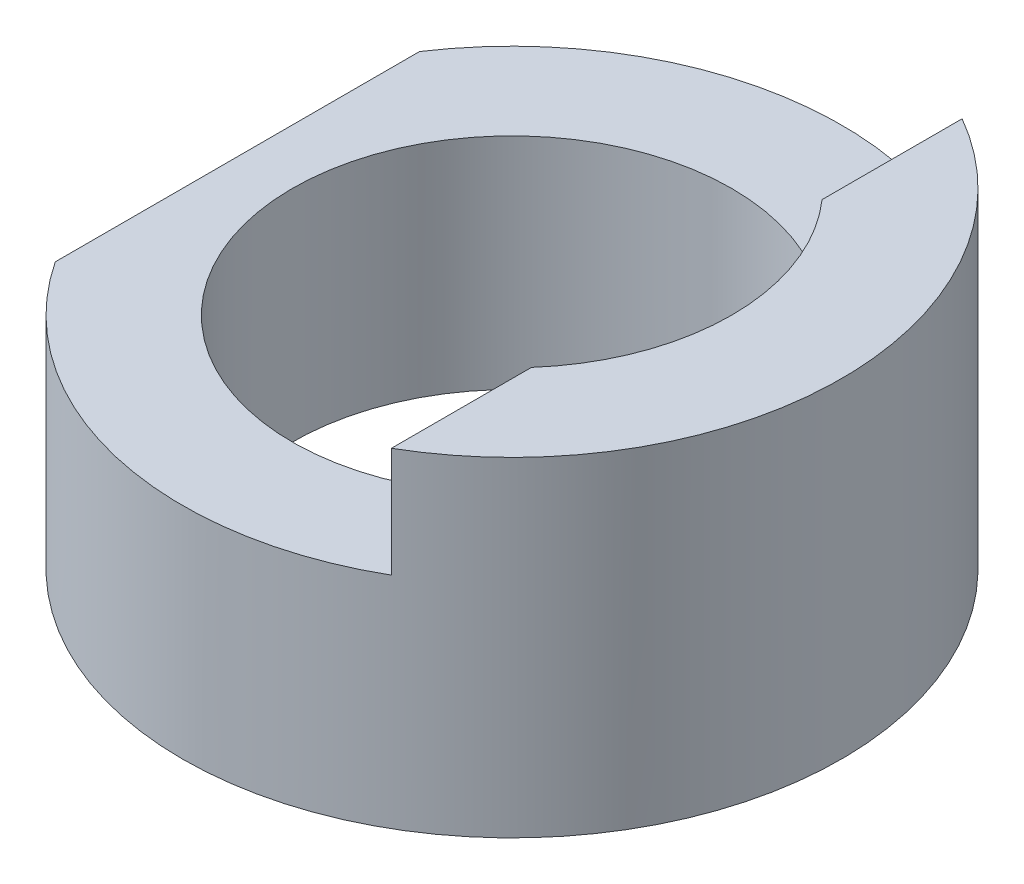
from build123d import *

# Parameters (mm, degrees)
SKETCH1_W           = 120
SKETCH1_H           = 60
BOSS_EXTRUDE1_DEPTH = 120
CUT_EXTRUDE1_DEPTH  = 120
CUT_EXTRUDE2_DEPTH  = 120
SKETCH5_R           = 40
CUT_EXTRUDE3_DEPTH  = 120


with BuildPart() as part:
    # Sketch1 → Boss-Extrude1 (new body)
    with BuildSketch(Plane.XY):
        with Locations((60, 30)):
            Rectangle(SKETCH1_W, SKETCH1_H)
    extrude(amount=BOSS_EXTRUDE1_DEPTH)

    # Sketch2 → Cut-Extrude1 (cut)
    with BuildSketch(Plane.XY.offset(120)):
        Polygon((0, 60), (0, 20), (10, 20), (10, 40), (90, 40), (90, 60), align=None)
    extrude(amount=-CUT_EXTRUDE1_DEPTH, mode=Mode.SUBTRACT)

    # Sketch3 → Cut-Extrude2 (cut)
    with BuildSketch(Plane(origin=(0, 0, 0), x_dir=(1, 0, 0), z_dir=(0, 1, 0))):
        with BuildLine():
            Line((120, 0), (60, 0))
            ThreePointArc((60, 0), (102.426406871, -17.573593129), (120, -60))
            Line((120, -60), (120, 0))
        make_face()
        with BuildLine():
            ThreePointArc((0, -60), (17.573593129, -17.573593129), (60, 0))
            Line((60, 0), (0, 0))
            Line((0, 0), (0, -60))
        make_face()
        with BuildLine():
            ThreePointArc((60, -120), (17.573593129, -102.426406871), (0, -60))
            Line((0, -60), (0, -120))
            Line((0, -120), (60, -120))
        make_face()
        with BuildLine():
            Line((120, -120), (120, -60))
            ThreePointArc((120, -60), (102.426406871, -102.426406871), (60, -120))
            Line((60, -120), (120, -120))
        make_face()
    extrude(amount=CUT_EXTRUDE2_DEPTH, mode=Mode.SUBTRACT)

    # Sketch5 → Cut-Extrude3 (cut)
    with BuildSketch(Plane(origin=(0, 0, 0), x_dir=(-1, 0, 0), z_dir=(0, -1, 0))):
        with Locations((-60, -60)):
            Circle(SKETCH5_R)
    extrude(amount=-CUT_EXTRUDE3_DEPTH, mode=Mode.SUBTRACT)


solid = part.part
